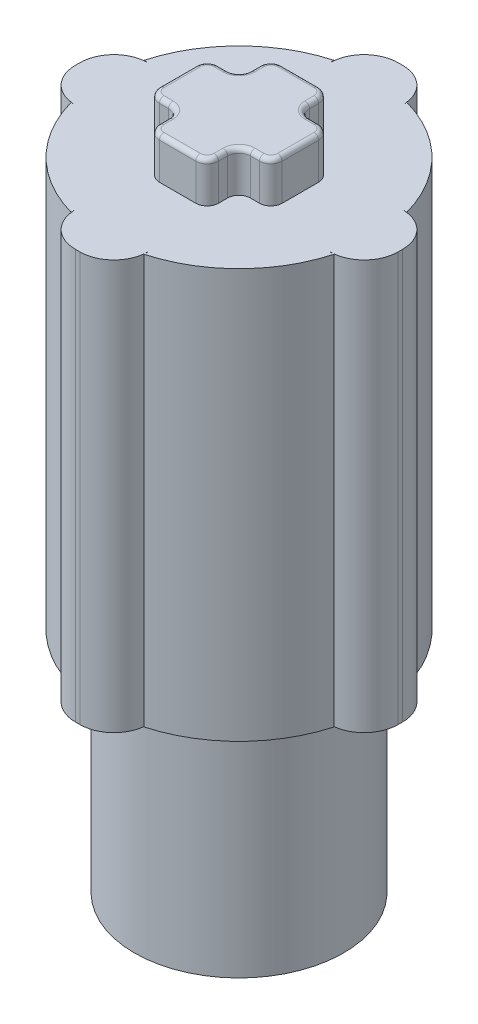
from build123d import *

# Parameters (mm, degrees)
SKETCH1_R           = 2.3
BOSS_EXTRUDE1_DEPTH = 5
BOSS_EXTRUDE2_DEPTH = 9
BOSS_EXTRUDE3_DEPTH = 0.9
FILLET2_R           = 0.1


with BuildPart() as part:
    # Sketch1 → Boss-Extrude1 (new body)
    with BuildSketch(Plane(origin=(0, 0, 0), x_dir=(1, 0, 0), z_dir=(0, 1, 0))):
        Circle(SKETCH1_R)
    extrude(amount=BOSS_EXTRUDE1_DEPTH)

    # Sketch2 → Boss-Extrude2 (add)
    with BuildSketch(Plane(origin=(0, 5, 0), x_dir=(1, 0, 0), z_dir=(0, 1, 0))):
        with BuildLine():
            Line((0.05, 3.55), (-0.05, 3.55))
            ThreePointArc((-0.05, 3.55), (-0.580330086, 3.330330086), (-0.8, 2.8))
            Line((-0.8, 2.8), (-0.8, 2.891366459))
            ThreePointArc((-0.8, 2.891366459), (-2.121320344, 2.121320344), (-2.891366459, 0.8))
            Line((-2.891366459, 0.8), (-2.8, 0.8))
            ThreePointArc((-2.8, 0.8), (-3.330330086, 0.580330086), (-3.55, 0.05))
            Line((-3.55, 0.05), (-3.55, -0.05))
            ThreePointArc((-3.55, -0.05), (-3.330330086, -0.580330086), (-2.8, -0.8))
            Line((-2.8, -0.8), (-2.891366459, -0.8))
            ThreePointArc((-2.891366459, -0.8), (-2.121320344, -2.121320344), (-0.8, -2.891366459))
            Line((-0.8, -2.891366459), (-0.8, -2.8))
            ThreePointArc((-0.8, -2.8), (-0.580330086, -3.330330086), (-0.05, -3.55))
            Line((-0.05, -3.55), (0.05, -3.55))
            ThreePointArc((0.05, -3.55), (0.580330086, -3.330330086), (0.8, -2.8))
            Line((0.8, -2.8), (0.8, -2.891366459))
            ThreePointArc((0.8, -2.891366459), (2.121320344, -2.121320344), (2.891366459, -0.8))
            Line((2.891366459, -0.8), (2.8, -0.8))
            ThreePointArc((2.8, -0.8), (3.330330086, -0.580330086), (3.55, -0.05))
            Line((3.55, -0.05), (3.55, 0.05))
            ThreePointArc((3.55, 0.05), (3.330330086, 0.580330086), (2.8, 0.8))
            Line((2.8, 0.8), (2.891366459, 0.8))
            ThreePointArc((2.891366459, 0.8), (2.121320344, 2.121320344), (0.8, 2.891366459))
            Line((0.8, 2.891366459), (0.8, 2.8))
            ThreePointArc((0.8, 2.8), (0.580330086, 3.330330086), (0.05, 3.55))
        make_face()
    extrude(amount=BOSS_EXTRUDE2_DEPTH)

    # Sketch3 → Boss-Extrude3 (add)
    with BuildSketch(Plane(origin=(0, 14, 0), x_dir=(1, 0, 0), z_dir=(0, 1, 0))):
        with BuildLine():
            Line((-0.4, 1.35), (0.4, 1.35))
            ThreePointArc((0.4, 1.35), (0.576776695, 1.276776695), (0.65, 1.1))
            Line((0.65, 1.1), (0.65, 0.9))
            ThreePointArc((0.65, 0.9), (0.723223305, 0.723223305), (0.9, 0.65))
            Line((0.9, 0.65), (1.1, 0.65))
            ThreePointArc((1.1, 0.65), (1.276776695, 0.576776695), (1.35, 0.4))
            Line((1.35, 0.4), (1.35, -0.4))
            ThreePointArc((1.35, -0.4), (1.276776695, -0.576776695), (1.1, -0.65))
            Line((1.1, -0.65), (0.9, -0.65))
            ThreePointArc((0.9, -0.65), (0.723223305, -0.723223305), (0.65, -0.9))
            Line((0.65, -0.9), (0.65, -1.1))
            ThreePointArc((0.65, -1.1), (0.576776695, -1.276776695), (0.4, -1.35))
            Line((0.4, -1.35), (-0.4, -1.35))
            ThreePointArc((-0.4, -1.35), (-0.576776695, -1.276776695), (-0.65, -1.1))
            Line((-0.65, -1.1), (-0.65, -0.9))
            ThreePointArc((-0.65, -0.9), (-0.723223305, -0.723223305), (-0.9, -0.65))
            Line((-0.9, -0.65), (-1.1, -0.65))
            ThreePointArc((-1.1, -0.65), (-1.276776695, -0.576776695), (-1.35, -0.4))
            Line((-1.35, -0.4), (-1.35, 0.4))
            ThreePointArc((-1.35, 0.4), (-1.276776695, 0.576776695), (-1.1, 0.65))
            Line((-1.1, 0.65), (-0.9, 0.65))
            ThreePointArc((-0.9, 0.65), (-0.723223305, 0.723223305), (-0.65, 0.9))
            Line((-0.65, 0.9), (-0.65, 1.1))
            ThreePointArc((-0.65, 1.1), (-0.576776695, 1.276776695), (-0.4, 1.35))
        make_face()
    extrude(amount=BOSS_EXTRUDE3_DEPTH)

    # Fillet2
    fillet2_edges = [part.edges().sort_by_distance(p)[0] for p in [
        (0.723223305, 14.9, 0.723223305),
        (1, 14.9, 0.65),
        (1.276776695, 14.9, 0.576776695),
        (1.35, 14.9, 0),
        (1.276776695, 14.9, -0.576776695),
        (1, 14.9, -0.65),
        (0.723223305, 14.9, -0.723223305),
        (0.65, 14.9, -1),
        (0.576776695, 14.9, -1.276776695),
        (0, 14.9, -1.35),
        (-0.576776695, 14.9, -1.276776695),
        (-0.65, 14.9, -1),
        (-0.723223305, 14.9, -0.723223305),
        (-1, 14.9, -0.65),
        (-1.276776695, 14.9, -0.576776695),
        (-1.35, 14.9, 0),
        (-1.276776695, 14.9, 0.576776695),
        (-1, 14.9, 0.65),
        (-0.723223305, 14.9, 0.723223305),
        (-0.65, 14.9, 1),
        (-0.576776695, 14.9, 1.276776695),
        (0, 14.9, 1.35),
        (0.576776695, 14.9, 1.276776695),
        (0.65, 14.9, 1),
    ]]
    fillet(fillet2_edges, radius=FILLET2_R)


solid = part.part
